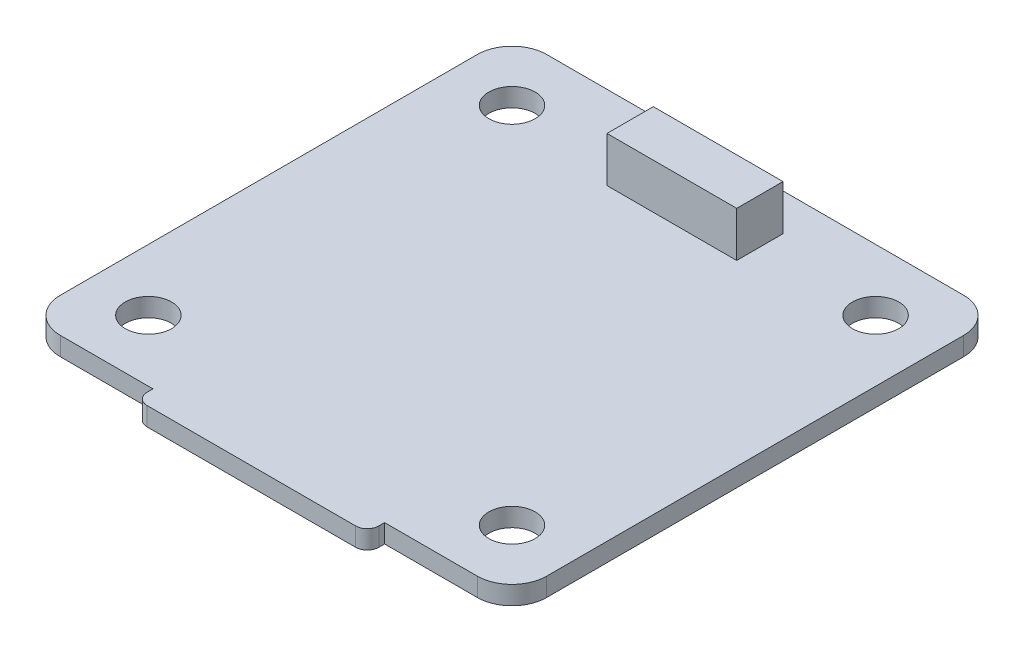
from build123d import *

# Parameters (mm, degrees)
DODANIE_WYCI_GNI_CIE1_DEPTH = 1.6
SZKIC2_3_R                  = 2
WYTNIJ_WYCI_GNI_CIE1_DEPTH  = 1.6
SZKIC3_W                    = 11.2
SZKIC3_H                    = 4
DODANIE_WYCI_GNI_CIE2_DEPTH = 3.9


with BuildPart() as part:
    # Szkic2 → Dodanie-wyci_gni_cie1 (new body)
    with BuildSketch(Plane(origin=(0, 0, 0), x_dir=(1, 0, 0), z_dir=(0, 1, 0))):
        with BuildLine():
            Line((-10, -21), (-10, -21.5))
            ThreePointArc((-10, -21.5), (-9.707106781, -22.207106781), (-9, -22.5))
            Line((-9, -22.5), (9, -22.5))
            ThreePointArc((9, -22.5), (9.707106781, -22.207106781), (10, -21.5))
            Line((10, -21.5), (10, -21))
            Line((10, -21), (18, -21))
            ThreePointArc((18, -21), (20.121320344, -20.121320344), (21, -18))
            Line((21, -18), (21, 18))
            ThreePointArc((21, 18), (20.121320344, 20.121320344), (18, 21))
            Line((18, 21), (-18, 21))
            ThreePointArc((-18, 21), (-20.121320344, 20.121320344), (-21, 18))
            Line((-21, 18), (-21, -18))
            ThreePointArc((-21, -18), (-20.121320344, -20.121320344), (-18, -21))
            Line((-18, -21), (-10, -21))
        make_face()
    extrude(amount=DODANIE_WYCI_GNI_CIE1_DEPTH)

    # Szkic2_3 → Wytnij-wyci_gni_cie1 (cut)
    with BuildSketch(Plane(origin=(0, 0, 0), x_dir=(1, 0, 0), z_dir=(0, 1, 0))):
        with Locations((15.696699141, 15.696699141)):
            Circle(SZKIC2_3_R)
        with Locations((-15.696699141, 15.696699141)):
            Circle(SZKIC2_3_R)
        with Locations((15.696699141, -15.696699141)):
            Circle(SZKIC2_3_R)
        with Locations((-15.696699141, -15.696699141)):
            Circle(SZKIC2_3_R)
    extrude(amount=WYTNIJ_WYCI_GNI_CIE1_DEPTH, mode=Mode.SUBTRACT)

    # Szkic3 → Dodanie-wyci_gni_cie2 (add)
    with BuildSketch(Plane(origin=(0, 1.6, 0), x_dir=(1, 0, 0), z_dir=(0, 1, 0))):
        with Locations((0, 15.8)):
            Rectangle(SZKIC3_W, SZKIC3_H)
    extrude(amount=DODANIE_WYCI_GNI_CIE2_DEPTH)


solid = part.part
